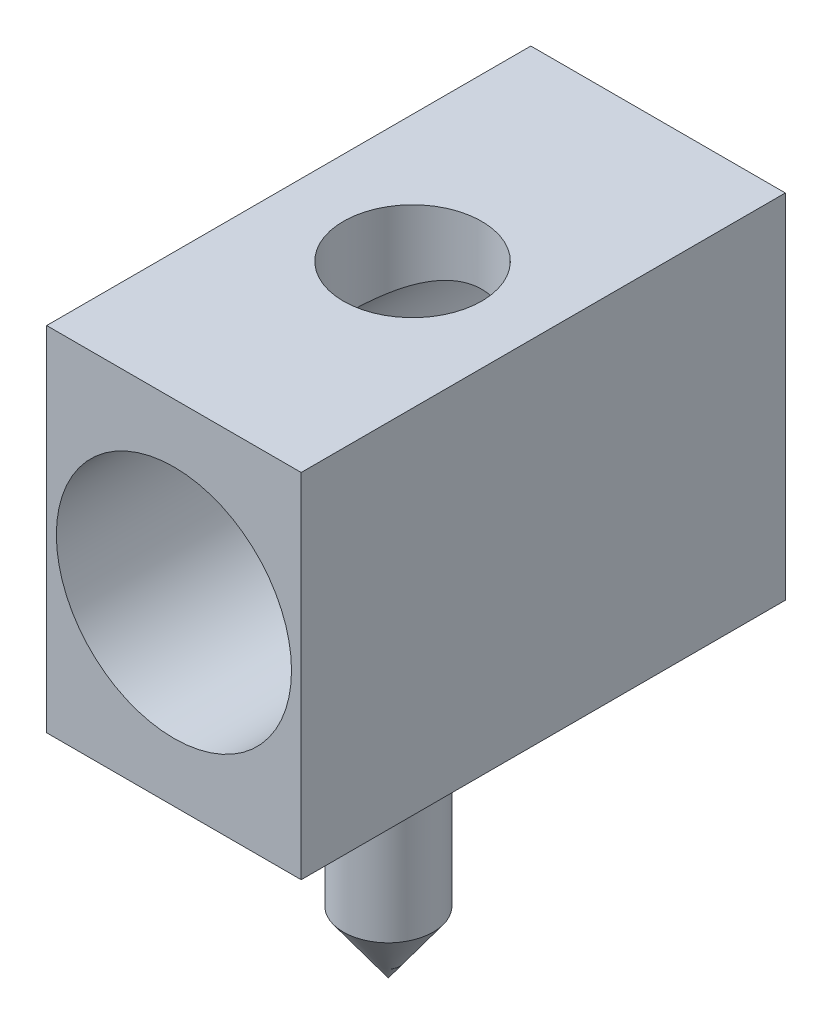
from build123d import *

# Parameters (mm, degrees)
SKETCH1_W           = 3.68
SKETCH1_H           = 7
BOSS_EXTRUDE1_DEPTH = 5.1
SKETCH2_R           = 1.7
CUT_EXTRUDE1_DEPTH  = 6.5
SKETCH3_R           = 0.65
BOSS_EXTRUDE2_DEPTH = 2.8
CUT_EXTRUDE2_REACH  = 9.9
SKETCH4_R           = 1


with BuildPart() as part:
    # Sketch1 → Boss-Extrude1 (new body)
    with BuildSketch(Plane(origin=(0, 0, 0), x_dir=(1, 0, 0), z_dir=(0, 1, 0))):
        with Locations((-1.84, -3.5)):
            Rectangle(SKETCH1_W, SKETCH1_H)
    extrude(amount=BOSS_EXTRUDE1_DEPTH)

    # Sketch2 → Cut-Extrude1 (cut)
    with BuildSketch(Plane.XY.offset(7)):
        with Locations((-1.84, 2.55)):
            Circle(SKETCH2_R)
    extrude(amount=-CUT_EXTRUDE1_DEPTH, mode=Mode.SUBTRACT)

    # Sketch3 → Boss-Extrude2 (add)
    with BuildSketch(Plane.XZ):
        with Locations((-1.84, 3.9)):
            Circle(SKETCH3_R)
    extrude(amount=BOSS_EXTRUDE2_DEPTH)

    # Sketch4 → Cut-Extrude2 (cut, up to next)
    with BuildSketch(Plane(origin=(0, 5.1, 0), x_dir=(1, 0, 0), z_dir=(0, 1, 0)), mode=Mode.PRIVATE) as cut_extrude2_sk1:
        with Locations((-1.84, -3.55)):
            Circle(SKETCH4_R)
    cut_extrude2_tool1 = extrude(cut_extrude2_sk1.sketch, amount=-CUT_EXTRUDE2_REACH, mode=Mode.PRIVATE) & part.part
    add(cut_extrude2_tool1.solids().sort_by_distance((-1.84, 5.1, 3.55))[0], mode=Mode.SUBTRACT)

    # Sketch7 → Revolve2 (revolve)
    with BuildSketch(Plane(origin=(-1.84, 0, 0), x_dir=(0, 0, -1), z_dir=(1, 0, 0))):
        Polygon((-3.9, -2.8), (-3.9, -3.7), (-4.55, -2.8), align=None)
    revolve(axis=Axis((-1.84, -2.8, 3.9), (0, -1, 0)))


solid = part.part
